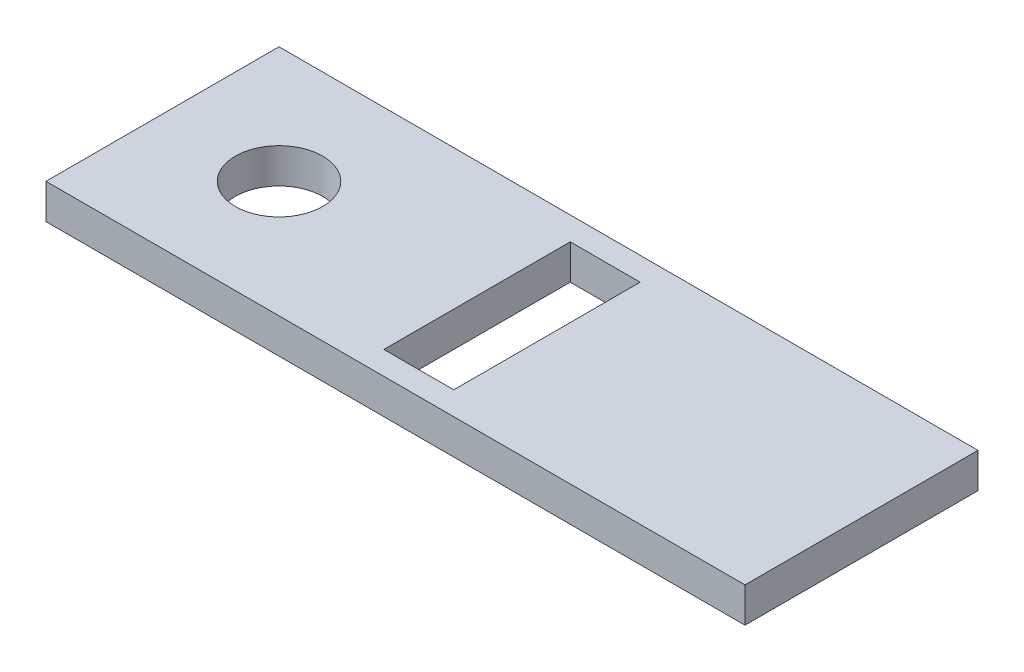
from build123d import *

# Parameters (mm, degrees)
SKETCH1_W           = 152.4
SKETCH1_H           = 50.8
BOSS_EXTRUDE1_DEPTH = 7.62
SKETCH3_R           = 9.525
CUT_EXTRUDE2_DEPTH  = 8.62
SKETCH5_W           = 15.24
SKETCH5_H           = 40.64
CUT_EXTRUDE4_DEPTH  = 8.62


with BuildPart() as part:
    # Sketch1 → Boss-Extrude1 (new body)
    with BuildSketch(Plane(origin=(0, 0, 0), x_dir=(1, 0, 0), z_dir=(0, 1, 0))):
        Rectangle(SKETCH1_W, SKETCH1_H)
    extrude(amount=BOSS_EXTRUDE1_DEPTH)

    # Sketch3 → Cut-Extrude2 (cut, through all)
    with BuildSketch(Plane(origin=(0, 7.62, 0), x_dir=(1, 0, 0), z_dir=(0, 1, 0))):
        with Locations((-50.8, 0)):
            Circle(SKETCH3_R)
    extrude(amount=-CUT_EXTRUDE2_DEPTH, mode=Mode.SUBTRACT)

    # Sketch5 → Cut-Extrude4 (cut, through all)
    with BuildSketch(Plane(origin=(0, 7.62, 0), x_dir=(1, 0, 0), z_dir=(0, 1, 0))):
        Rectangle(SKETCH5_W, SKETCH5_H)
    extrude(amount=-CUT_EXTRUDE4_DEPTH, mode=Mode.SUBTRACT)


solid = part.part
